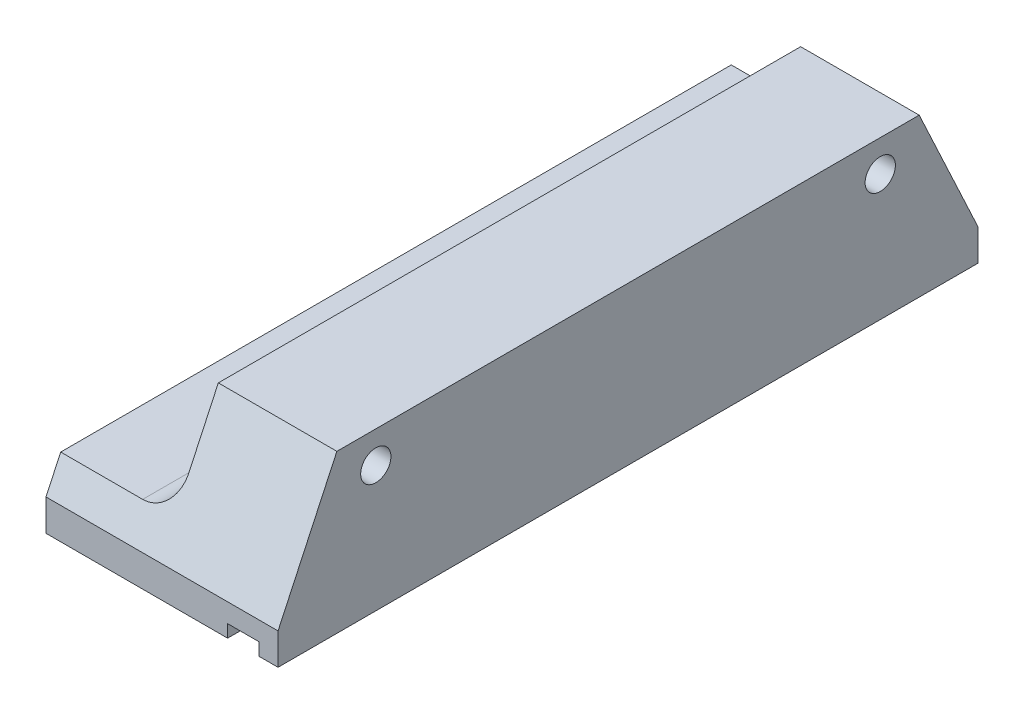
from build123d import *

# Parameters (mm, degrees)
SKETCH1_W                       = 18.4
SKETCH1_H                       = 12.5
BOSS_EXTRUDE1_DEPTH             = 55.5
SKETCH2_W                       = 2.5
SKETCH2_H                       = 1
CUT_EXTRUDE1_DEPTH              = 56.5
M2X0_4_TAPPED_HOLE1_D           = 1.6
M2X0_4_TAPPED_HOLE1_DEPTH       = 6.5
M2X0_4_TAPPED_HOLE1_CBORE_D     = 2
M2X0_4_TAPPED_HOLE1_CBORE_DEPTH = 4.5
M2X0_4_TAPPED_HOLE1_TIP         = 0.480688495
CBORE_FOR_M2_SHCS1_D            = 2.4
CBORE_FOR_M2_SHCS1_CBORE_D      = 4.4
CBORE_FOR_M2_SHCS1_CBORE_DEPTH  = 10.9
CHAMFER1_SIZE                   = 10
CHAMFER1_SIZE2                  = 4.663076582
CHAMFER2_SIZE                   = 10
CHAMFER2_SIZE2                  = 4.663076582
SKETCH7_W                       = 55.5
SKETCH7_H                       = 7.5
CUT_EXTRUDE2_DEPTH              = 9
FILLET2_R                       = 2.5


with BuildPart() as part:
    # Sketch1 → Boss-Extrude1 (new body)
    with BuildSketch(Plane.XY):
        with Locations((-9.2, 6.25)):
            Rectangle(SKETCH1_W, SKETCH1_H)
    extrude(amount=BOSS_EXTRUDE1_DEPTH)

    # Sketch2 → Cut-Extrude1 (cut, through all)
    with BuildSketch(Plane.XY.offset(55.5)):
        with Locations((-2.75, 0.5)):
            Rectangle(SKETCH2_W, SKETCH2_H)
    extrude(amount=-CUT_EXTRUDE1_DEPTH, mode=Mode.SUBTRACT)

    # M2x0.4 Tapped Hole1
    with Locations(Plane.ZY.offset(18.4)):
        with Locations((51.75, 3), (27.75, 3), (3.75, 3)):
            CounterBoreHole(M2X0_4_TAPPED_HOLE1_D / 2, M2X0_4_TAPPED_HOLE1_CBORE_D / 2, M2X0_4_TAPPED_HOLE1_CBORE_DEPTH, depth=M2X0_4_TAPPED_HOLE1_DEPTH)
            with Locations((0, 0, -(M2X0_4_TAPPED_HOLE1_DEPTH + M2X0_4_TAPPED_HOLE1_TIP / 2))):  # 118° drill point
                Cone(0, M2X0_4_TAPPED_HOLE1_D / 2, M2X0_4_TAPPED_HOLE1_TIP, mode=Mode.SUBTRACT)

    # CBORE for M2 SHCS1 (through all)
    with Locations(Plane.ZY.offset(18.4)):
        with Locations((47.75, 10), (7.75, 10)):
            CounterBoreHole(CBORE_FOR_M2_SHCS1_D / 2, CBORE_FOR_M2_SHCS1_CBORE_D / 2, CBORE_FOR_M2_SHCS1_CBORE_DEPTH)

    # Chamfer1
    chamfer1_edges = [part.edges().sort_by_distance(p)[0] for p in [
        (-9.2, 12.5, 0),
    ]]
    chamfer1_side = [part.faces().sort_by_distance(p)[0] for p in [
        (-9.270879121, 6.313186813, 0),
    ]]
    chamfer(chamfer1_edges, length=CHAMFER1_SIZE, length2=CHAMFER1_SIZE2, reference=chamfer1_side[0])

    # Chamfer2
    chamfer2_edges = [part.edges().sort_by_distance(p)[0] for p in [
        (-9.2, 12.5, 55.5),
    ]]
    chamfer2_side = [part.faces().sort_by_distance(p)[0] for p in [
        (-9.270879121, 6.313186813, 55.5),
    ]]
    chamfer(chamfer2_edges, length=CHAMFER2_SIZE, length2=CHAMFER2_SIZE2, reference=chamfer2_side[0])

    # Sketch7 → Cut-Extrude2 (cut)
    with BuildSketch(Plane.ZY.offset(18.4)):
        with Locations((27.75, 8.75)):
            Rectangle(SKETCH7_W, SKETCH7_H)
    extrude(amount=-CUT_EXTRUDE2_DEPTH, mode=Mode.SUBTRACT)

    # Fillet2
    fillet2_edges = [part.edges().sort_by_distance(p)[0] for p in [
        (-9.4, 5, 27.75),
    ]]
    fillet(fillet2_edges, radius=FILLET2_R)


solid = part.part
